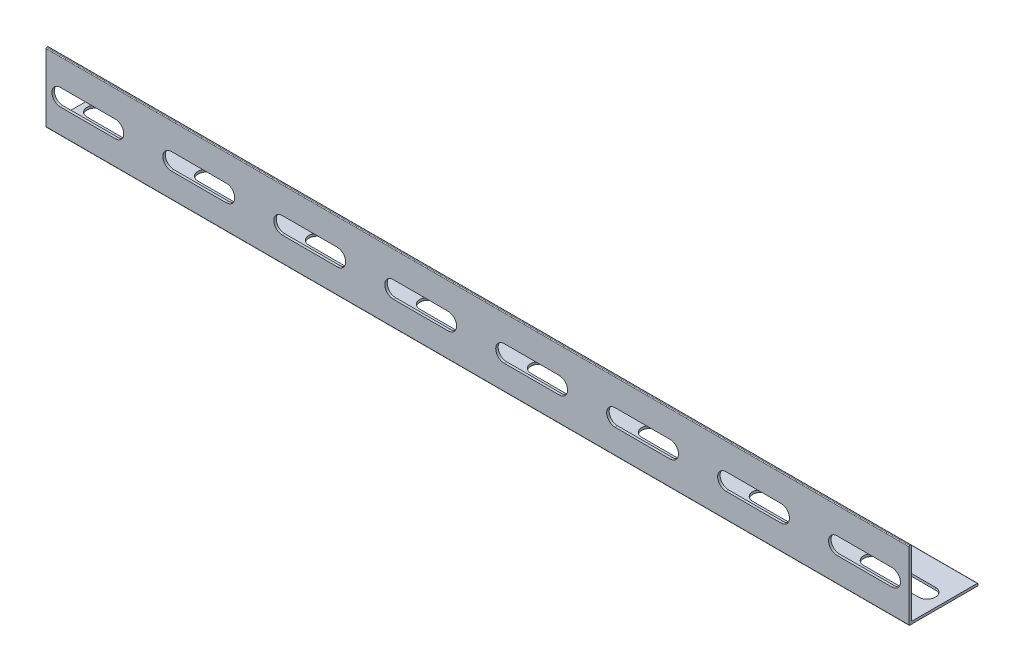
from build123d import *

# Parameters (mm, degrees)
EXTRUDE_1_DEPTH     = 350
CUT_EXTRUDE_1_REACH = 30
CUT_EXTRUDE_2_REACH = 3


with BuildPart() as part:
    # 草图1 → 凸台-拉伸1 (new body)
    with BuildSketch(Plane(origin=(0, 0, 0), x_dir=(0, 0, -1), z_dir=(1, 0, 0))):
        with BuildLine():
            Line((0, 0), (-5.481376518, 0))
            ThreePointArc((-5.481376518, 0), (-5.693508553, 0.087867966), (-5.781376518, 0.3))
            Line((-5.781376518, 0.3), (-5.781376518, 27.7))
            ThreePointArc((-5.781376518, 27.7), (-5.693508553, 27.912132034), (-5.481376518, 28))
            Line((-5.481376518, 28), (-5.081376518, 28))
            ThreePointArc((-5.081376518, 28), (-4.869244484, 27.912132034), (-4.781376518, 27.7))
            Line((-4.781376518, 27.7), (-4.781376518, 1.3))
            ThreePointArc((-4.781376518, 1.3), (-4.693508553, 1.087867966), (-4.481376518, 1))
            Line((-4.481376518, 1), (21.918623482, 1))
            ThreePointArc((21.918623482, 1), (22.130755516, 0.912132034), (22.218623482, 0.7))
            Line((22.218623482, 0.7), (22.218623482, 0.3))
            ThreePointArc((22.218623482, 0.3), (22.130755516, 0.087867966), (21.918623482, 0))
            Line((21.918623482, 0), (0, 0))
        make_face()
    extrude(amount=EXTRUDE_1_DEPTH)

    # 草图2 → 切除-拉伸1 (cut, up to next)
    with BuildSketch(Plane.XY.offset(5.781376518), mode=Mode.PRIVATE) as cut_extrude_1_sk1:
        with BuildLine():
            Line((5.834676913, 16.979123609), (28.090979636, 16.979123609))
            ThreePointArc((28.090979636, 16.979123609), (31.526327183, 13.543776063), (28.090979636, 10.108428517))
            Line((28.090979636, 10.108428517), (5.834676913, 10.108428517))
            ThreePointArc((5.834676913, 10.108428517), (2.399329367, 13.543776063), (5.834676913, 16.979123609))
        make_face()
    cut_extrude_1_tool1 = extrude(cut_extrude_1_sk1.sketch, amount=-CUT_EXTRUDE_1_REACH, mode=Mode.PRIVATE) & part.part
    add(cut_extrude_1_tool1.solids().sort_by_distance((16.962828, 13.543776, 5.781377))[0], mode=Mode.SUBTRACT)
    # 草图2 → 切除-拉伸1 (cut, up to next)
    with BuildSketch(Plane.XY.offset(5.781376518), mode=Mode.PRIVATE) as cut_extrude_1_sk2:
        with BuildLine():
            Line((50.834676913, 16.979123609), (73.090979636, 16.979123609))
            ThreePointArc((73.090979636, 16.979123609), (76.526327183, 13.543776063), (73.090979636, 10.108428517))
            Line((73.090979636, 10.108428517), (50.834676913, 10.108428517))
            ThreePointArc((50.834676913, 10.108428517), (47.399329367, 13.543776063), (50.834676913, 16.979123609))
        make_face()
    cut_extrude_1_tool2 = extrude(cut_extrude_1_sk2.sketch, amount=-CUT_EXTRUDE_1_REACH, mode=Mode.PRIVATE) & part.part
    add(cut_extrude_1_tool2.solids().sort_by_distance((61.962828, 13.543776, 5.781377))[0], mode=Mode.SUBTRACT)
    # 草图2 → 切除-拉伸1 (cut, up to next)
    with BuildSketch(Plane.XY.offset(5.781376518), mode=Mode.PRIVATE) as cut_extrude_1_sk3:
        with BuildLine():
            Line((95.834676913, 16.979123609), (118.090979636, 16.979123609))
            ThreePointArc((118.090979636, 16.979123609), (121.526327183, 13.543776063), (118.090979636, 10.108428517))
            Line((118.090979636, 10.108428517), (95.834676913, 10.108428517))
            ThreePointArc((95.834676913, 10.108428517), (92.399329367, 13.543776063), (95.834676913, 16.979123609))
        make_face()
    cut_extrude_1_tool3 = extrude(cut_extrude_1_sk3.sketch, amount=-CUT_EXTRUDE_1_REACH, mode=Mode.PRIVATE) & part.part
    add(cut_extrude_1_tool3.solids().sort_by_distance((106.962828, 13.543776, 5.781377))[0], mode=Mode.SUBTRACT)
    # 草图2 → 切除-拉伸1 (cut, up to next)
    with BuildSketch(Plane.XY.offset(5.781376518), mode=Mode.PRIVATE) as cut_extrude_1_sk4:
        with BuildLine():
            Line((140.834676913, 16.979123609), (163.090979636, 16.979123609))
            ThreePointArc((163.090979636, 16.979123609), (166.526327183, 13.543776063), (163.090979636, 10.108428517))
            Line((163.090979636, 10.108428517), (140.834676913, 10.108428517))
            ThreePointArc((140.834676913, 10.108428517), (137.399329367, 13.543776063), (140.834676913, 16.979123609))
        make_face()
    cut_extrude_1_tool4 = extrude(cut_extrude_1_sk4.sketch, amount=-CUT_EXTRUDE_1_REACH, mode=Mode.PRIVATE) & part.part
    add(cut_extrude_1_tool4.solids().sort_by_distance((151.962828, 13.543776, 5.781377))[0], mode=Mode.SUBTRACT)
    # 草图2 → 切除-拉伸1 (cut, up to next)
    with BuildSketch(Plane.XY.offset(5.781376518), mode=Mode.PRIVATE) as cut_extrude_1_sk5:
        with BuildLine():
            Line((185.834676913, 16.979123609), (208.090979636, 16.979123609))
            ThreePointArc((208.090979636, 16.979123609), (211.526327183, 13.543776063), (208.090979636, 10.108428517))
            Line((208.090979636, 10.108428517), (185.834676913, 10.108428517))
            ThreePointArc((185.834676913, 10.108428517), (182.399329367, 13.543776063), (185.834676913, 16.979123609))
        make_face()
    cut_extrude_1_tool5 = extrude(cut_extrude_1_sk5.sketch, amount=-CUT_EXTRUDE_1_REACH, mode=Mode.PRIVATE) & part.part
    add(cut_extrude_1_tool5.solids().sort_by_distance((196.962828, 13.543776, 5.781377))[0], mode=Mode.SUBTRACT)
    # 草图2 → 切除-拉伸1 (cut, up to next)
    with BuildSketch(Plane.XY.offset(5.781376518), mode=Mode.PRIVATE) as cut_extrude_1_sk6:
        with BuildLine():
            Line((230.834676913, 16.979123609), (253.090979636, 16.979123609))
            ThreePointArc((253.090979636, 16.979123609), (256.526327183, 13.543776063), (253.090979636, 10.108428517))
            Line((253.090979636, 10.108428517), (230.834676913, 10.108428517))
            ThreePointArc((230.834676913, 10.108428517), (227.399329367, 13.543776063), (230.834676913, 16.979123609))
        make_face()
    cut_extrude_1_tool6 = extrude(cut_extrude_1_sk6.sketch, amount=-CUT_EXTRUDE_1_REACH, mode=Mode.PRIVATE) & part.part
    add(cut_extrude_1_tool6.solids().sort_by_distance((241.962828, 13.543776, 5.781377))[0], mode=Mode.SUBTRACT)
    # 草图2 → 切除-拉伸1 (cut, up to next)
    with BuildSketch(Plane.XY.offset(5.781376518), mode=Mode.PRIVATE) as cut_extrude_1_sk7:
        with BuildLine():
            Line((275.834676913, 16.979123609), (298.090979636, 16.979123609))
            ThreePointArc((298.090979636, 16.979123609), (301.526327183, 13.543776063), (298.090979636, 10.108428517))
            Line((298.090979636, 10.108428517), (275.834676913, 10.108428517))
            ThreePointArc((275.834676913, 10.108428517), (272.399329367, 13.543776063), (275.834676913, 16.979123609))
        make_face()
    cut_extrude_1_tool7 = extrude(cut_extrude_1_sk7.sketch, amount=-CUT_EXTRUDE_1_REACH, mode=Mode.PRIVATE) & part.part
    add(cut_extrude_1_tool7.solids().sort_by_distance((286.962828, 13.543776, 5.781377))[0], mode=Mode.SUBTRACT)
    # 草图2 → 切除-拉伸1 (cut, up to next)
    with BuildSketch(Plane.XY.offset(5.781376518), mode=Mode.PRIVATE) as cut_extrude_1_sk8:
        with BuildLine():
            Line((320.834676913, 16.979123609), (343.090979636, 16.979123609))
            ThreePointArc((343.090979636, 16.979123609), (346.526327183, 13.543776063), (343.090979636, 10.108428517))
            Line((343.090979636, 10.108428517), (320.834676913, 10.108428517))
            ThreePointArc((320.834676913, 10.108428517), (317.399329367, 13.543776063), (320.834676913, 16.979123609))
        make_face()
    cut_extrude_1_tool8 = extrude(cut_extrude_1_sk8.sketch, amount=-CUT_EXTRUDE_1_REACH, mode=Mode.PRIVATE) & part.part
    add(cut_extrude_1_tool8.solids().sort_by_distance((331.962828, 13.543776, 5.781377))[0], mode=Mode.SUBTRACT)

    # 草图3 → 切除-拉伸2 (cut, up to next)
    with BuildSketch(Plane(origin=(0, 1, 0), x_dir=(1, 0, 0), z_dir=(0, 1, 0)), mode=Mode.PRIVATE) as cut_extrude_2_sk1:
        with BuildLine():
            Line((5.656501178, 12.068493885), (27.912803901, 12.068493885))
            ThreePointArc((27.912803901, 12.068493885), (31.348151448, 8.633146338), (27.912803901, 5.197798792))
            Line((27.912803901, 5.197798792), (5.656501178, 5.197798792))
            ThreePointArc((5.656501178, 5.197798792), (2.221153632, 8.633146338), (5.656501178, 12.068493885))
        make_face()
    cut_extrude_2_tool1 = extrude(cut_extrude_2_sk1.sketch, amount=-CUT_EXTRUDE_2_REACH, mode=Mode.PRIVATE) & part.part
    add(cut_extrude_2_tool1.solids().sort_by_distance((16.784653, 1, -8.633146))[0], mode=Mode.SUBTRACT)
    # 草图3 → 切除-拉伸2 (cut, up to next)
    with BuildSketch(Plane(origin=(0, 1, 0), x_dir=(1, 0, 0), z_dir=(0, 1, 0)), mode=Mode.PRIVATE) as cut_extrude_2_sk2:
        with BuildLine():
            Line((50.656501178, 12.068493885), (72.912803901, 12.068493885))
            ThreePointArc((72.912803901, 12.068493885), (76.348151448, 8.633146338), (72.912803901, 5.197798792))
            Line((72.912803901, 5.197798792), (50.656501178, 5.197798792))
            ThreePointArc((50.656501178, 5.197798792), (47.221153632, 8.633146338), (50.656501178, 12.068493885))
        make_face()
    cut_extrude_2_tool2 = extrude(cut_extrude_2_sk2.sketch, amount=-CUT_EXTRUDE_2_REACH, mode=Mode.PRIVATE) & part.part
    add(cut_extrude_2_tool2.solids().sort_by_distance((61.784653, 1, -8.633146))[0], mode=Mode.SUBTRACT)
    # 草图3 → 切除-拉伸2 (cut, up to next)
    with BuildSketch(Plane(origin=(0, 1, 0), x_dir=(1, 0, 0), z_dir=(0, 1, 0)), mode=Mode.PRIVATE) as cut_extrude_2_sk3:
        with BuildLine():
            Line((95.656501178, 12.068493885), (117.912803901, 12.068493885))
            ThreePointArc((117.912803901, 12.068493885), (121.348151448, 8.633146338), (117.912803901, 5.197798792))
            Line((117.912803901, 5.197798792), (95.656501178, 5.197798792))
            ThreePointArc((95.656501178, 5.197798792), (92.221153632, 8.633146338), (95.656501178, 12.068493885))
        make_face()
    cut_extrude_2_tool3 = extrude(cut_extrude_2_sk3.sketch, amount=-CUT_EXTRUDE_2_REACH, mode=Mode.PRIVATE) & part.part
    add(cut_extrude_2_tool3.solids().sort_by_distance((106.784653, 1, -8.633146))[0], mode=Mode.SUBTRACT)
    # 草图3 → 切除-拉伸2 (cut, up to next)
    with BuildSketch(Plane(origin=(0, 1, 0), x_dir=(1, 0, 0), z_dir=(0, 1, 0)), mode=Mode.PRIVATE) as cut_extrude_2_sk4:
        with BuildLine():
            Line((140.656501178, 12.068493885), (162.912803901, 12.068493885))
            ThreePointArc((162.912803901, 12.068493885), (166.348151448, 8.633146338), (162.912803901, 5.197798792))
            Line((162.912803901, 5.197798792), (140.656501178, 5.197798792))
            ThreePointArc((140.656501178, 5.197798792), (137.221153632, 8.633146338), (140.656501178, 12.068493885))
        make_face()
    cut_extrude_2_tool4 = extrude(cut_extrude_2_sk4.sketch, amount=-CUT_EXTRUDE_2_REACH, mode=Mode.PRIVATE) & part.part
    add(cut_extrude_2_tool4.solids().sort_by_distance((151.784653, 1, -8.633146))[0], mode=Mode.SUBTRACT)
    # 草图3 → 切除-拉伸2 (cut, up to next)
    with BuildSketch(Plane(origin=(0, 1, 0), x_dir=(1, 0, 0), z_dir=(0, 1, 0)), mode=Mode.PRIVATE) as cut_extrude_2_sk5:
        with BuildLine():
            Line((185.656501178, 12.068493885), (207.912803901, 12.068493885))
            ThreePointArc((207.912803901, 12.068493885), (211.348151448, 8.633146338), (207.912803901, 5.197798792))
            Line((207.912803901, 5.197798792), (185.656501178, 5.197798792))
            ThreePointArc((185.656501178, 5.197798792), (182.221153632, 8.633146338), (185.656501178, 12.068493885))
        make_face()
    cut_extrude_2_tool5 = extrude(cut_extrude_2_sk5.sketch, amount=-CUT_EXTRUDE_2_REACH, mode=Mode.PRIVATE) & part.part
    add(cut_extrude_2_tool5.solids().sort_by_distance((196.784653, 1, -8.633146))[0], mode=Mode.SUBTRACT)
    # 草图3 → 切除-拉伸2 (cut, up to next)
    with BuildSketch(Plane(origin=(0, 1, 0), x_dir=(1, 0, 0), z_dir=(0, 1, 0)), mode=Mode.PRIVATE) as cut_extrude_2_sk6:
        with BuildLine():
            Line((230.656501178, 12.068493885), (252.912803901, 12.068493885))
            ThreePointArc((252.912803901, 12.068493885), (256.348151448, 8.633146338), (252.912803901, 5.197798792))
            Line((252.912803901, 5.197798792), (230.656501178, 5.197798792))
            ThreePointArc((230.656501178, 5.197798792), (227.221153632, 8.633146338), (230.656501178, 12.068493885))
        make_face()
    cut_extrude_2_tool6 = extrude(cut_extrude_2_sk6.sketch, amount=-CUT_EXTRUDE_2_REACH, mode=Mode.PRIVATE) & part.part
    add(cut_extrude_2_tool6.solids().sort_by_distance((241.784653, 1, -8.633146))[0], mode=Mode.SUBTRACT)
    # 草图3 → 切除-拉伸2 (cut, up to next)
    with BuildSketch(Plane(origin=(0, 1, 0), x_dir=(1, 0, 0), z_dir=(0, 1, 0)), mode=Mode.PRIVATE) as cut_extrude_2_sk7:
        with BuildLine():
            Line((275.656501178, 12.068493885), (297.912803901, 12.068493885))
            ThreePointArc((297.912803901, 12.068493885), (301.348151448, 8.633146338), (297.912803901, 5.197798792))
            Line((297.912803901, 5.197798792), (275.656501178, 5.197798792))
            ThreePointArc((275.656501178, 5.197798792), (272.221153632, 8.633146338), (275.656501178, 12.068493885))
        make_face()
    cut_extrude_2_tool7 = extrude(cut_extrude_2_sk7.sketch, amount=-CUT_EXTRUDE_2_REACH, mode=Mode.PRIVATE) & part.part
    add(cut_extrude_2_tool7.solids().sort_by_distance((286.784653, 1, -8.633146))[0], mode=Mode.SUBTRACT)
    # 草图3 → 切除-拉伸2 (cut, up to next)
    with BuildSketch(Plane(origin=(0, 1, 0), x_dir=(1, 0, 0), z_dir=(0, 1, 0)), mode=Mode.PRIVATE) as cut_extrude_2_sk8:
        with BuildLine():
            Line((320.656501178, 12.068493885), (342.912803901, 12.068493885))
            ThreePointArc((342.912803901, 12.068493885), (346.348151448, 8.633146338), (342.912803901, 5.197798792))
            Line((342.912803901, 5.197798792), (320.656501178, 5.197798792))
            ThreePointArc((320.656501178, 5.197798792), (317.221153632, 8.633146338), (320.656501178, 12.068493885))
        make_face()
    cut_extrude_2_tool8 = extrude(cut_extrude_2_sk8.sketch, amount=-CUT_EXTRUDE_2_REACH, mode=Mode.PRIVATE) & part.part
    add(cut_extrude_2_tool8.solids().sort_by_distance((331.784653, 1, -8.633146))[0], mode=Mode.SUBTRACT)


solid = part.part
